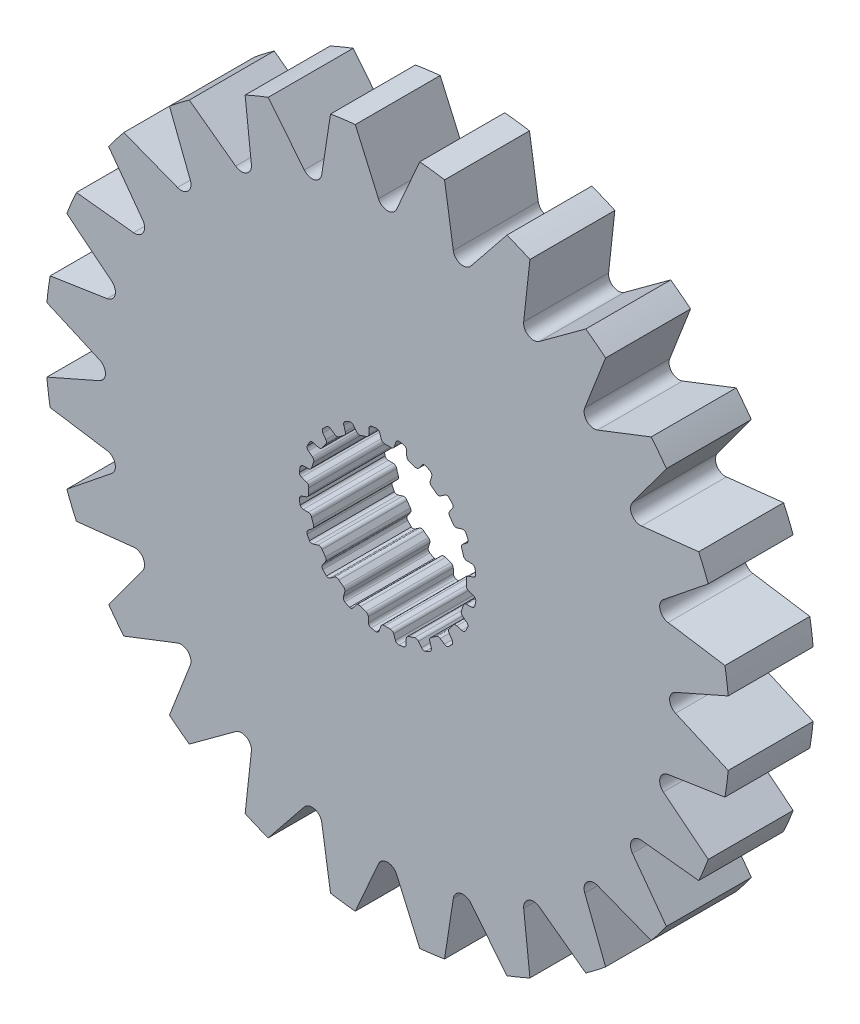
from build123d import *

# Parameters (mm, degrees)
SKETCH1_R           = 12.893401015
BOSS_EXTRUDE1_DEPTH = 1.6002
CUT_EXTRUDE1_DEPTH  = 3.2004


with BuildPart() as part:
    # Sketch1 → Boss-Extrude1 (new body, symmetric)
    with BuildSketch(Plane.XY):
        Circle(SKETCH1_R)
        with BuildLine():
            Line((-0.106949245, 2.969874934), (0.106949245, 2.969874934))
            ThreePointArc((0.106949245, 2.969874934), (0.196343213, 2.986924176), (0.253739238, 3.057547504))
            Line((0.253739238, 3.057547504), (0.315888147, 3.237526941))
            ThreePointArc((0.315888147, 3.237526941), (0.359032156, 3.298322911), (0.4281449, 3.326269005))
            Line((0.4281449, 3.326269005), (0.620027588, 3.2937547))
            ThreePointArc((0.620027588, 3.2937547), (0.689621142, 3.24802576), (0.718272212, 3.169836791))
            Line((0.718272212, 3.169836791), (0.724389167, 2.979527391))
            ThreePointArc((0.724389167, 2.979527391), (0.750934762, 2.9040661), (0.816027049, 2.857568043))
            Line((0.816027049, 2.857568043), (1.019456602, 2.791469774))
            ThreePointArc((1.019456602, 2.791469774), (1.109743823, 2.780060312), (1.186154496, 2.829490741))
            Line((1.186154496, 2.829490741), (1.300878326, 2.981456288))
            ThreePointArc((1.300878326, 2.981456288), (1.360697704, 3.02594446), (1.435063648, 3.031165762))
            Line((1.435063648, 3.031165762), (1.607507455, 2.940947809))
            ThreePointArc((1.607507455, 2.940947809), (1.659563839, 2.875951412), (1.662650905, 2.792735615))
            Line((1.662650905, 2.792735615), (1.609659636, 2.609850378))
            ThreePointArc((1.609659636, 2.609850378), (1.611587176, 2.529879385), (1.659124931, 2.465542482))
            Line((1.659124931, 2.465542482), (1.832172444, 2.339816104))
            ThreePointArc((1.832172444, 2.339816104), (1.914514976, 2.301064775), (2.002460687, 2.32446371))
            Line((2.002460687, 2.32446371), (2.158529469, 2.433539921))
            ThreePointArc((2.158529469, 2.433539921), (2.229168681, 2.457365482), (2.301508367, 2.439350895))
            Line((2.301508367, 2.439350895), (2.437633293, 2.300260456))
            ThreePointArc((2.437633293, 2.300260456), (2.467056864, 2.222358901), (2.444277744, 2.14226202))
            Line((2.444277744, 2.14226202), (2.337365406, 1.984703026))
            ThreePointArc((2.337365406, 1.984703026), (2.314486209, 1.908050449), (2.339816104, 1.832172444))
            Line((2.339816104, 1.832172444), (2.465542482, 1.659124931))
            ThreePointArc((2.465542482, 1.659124931), (2.531880064, 1.596824985), (2.622752074, 1.591901975))
            Line((2.622752074, 1.591901975), (2.804888709, 1.64741171))
            ThreePointArc((2.804888709, 1.64741171), (2.879433095, 1.648242449), (2.942665411, 1.608755366))
            Line((2.942665411, 1.608755366), (3.0291466, 1.434407582))
            ThreePointArc((3.0291466, 1.434407582), (3.033057175, 1.351226417), (2.986641646, 1.282088892))
            Line((2.986641646, 1.282088892), (2.836273564, 1.165279113))
            ThreePointArc((2.836273564, 1.165279113), (2.790827206, 1.099448241), (2.791469774, 1.019456602))
            Line((2.791469774, 1.019456602), (2.857568043, 0.816027049))
            ThreePointArc((2.857568043, 0.816027049), (2.901407091, 0.736276839), (2.986310214, 0.703513784))
            Line((2.986310214, 0.703513784), (3.1766859, 0.700023363))
            ThreePointArc((3.1766859, 0.700023363), (3.247838536, 0.677777961), (3.295773863, 0.620683653))
            Line((3.295773863, 0.620683653), (3.324145932, 0.4281449))
            ThreePointArc((3.324145932, 0.4281449), (3.302160717, 0.347826477), (3.236652255, 0.29641597))
            Line((3.236652255, 0.29641597), (3.057547504, 0.231789562))
            ThreePointArc((3.057547504, 0.231789562), (2.993982591, 0.183224379), (2.969874934, 0.106949245))
            Line((2.969874934, 0.106949245), (2.969874934, -0.106949245))
            ThreePointArc((2.969874934, -0.106949245), (2.986924176, -0.196343213), (3.057547504, -0.253739238))
            Line((3.057547504, -0.253739238), (3.237526941, -0.315888147))
            ThreePointArc((3.237526941, -0.315888147), (3.298322911, -0.359032156), (3.326269005, -0.4281449))
            Line((3.326269005, -0.4281449), (3.2937547, -0.620027588))
            ThreePointArc((3.2937547, -0.620027588), (3.24802576, -0.689621142), (3.169836791, -0.718272212))
            Line((3.169836791, -0.718272212), (2.979527391, -0.724389167))
            ThreePointArc((2.979527391, -0.724389167), (2.9040661, -0.750934762), (2.857568043, -0.816027049))
            Line((2.857568043, -0.816027049), (2.791469774, -1.019456602))
            ThreePointArc((2.791469774, -1.019456602), (2.780060312, -1.109743823), (2.829490741, -1.186154496))
            Line((2.829490741, -1.186154496), (2.981456288, -1.300878326))
            ThreePointArc((2.981456288, -1.300878326), (3.02594446, -1.360697704), (3.031165762, -1.435063648))
            Line((3.031165762, -1.435063648), (2.940947809, -1.607507455))
            ThreePointArc((2.940947809, -1.607507455), (2.875951412, -1.659563839), (2.792735615, -1.662650905))
            Line((2.792735615, -1.662650905), (2.609850378, -1.609659636))
            ThreePointArc((2.609850378, -1.609659636), (2.529879385, -1.611587176), (2.465542482, -1.659124931))
            Line((2.465542482, -1.659124931), (2.339816104, -1.832172444))
            ThreePointArc((2.339816104, -1.832172444), (2.301064775, -1.914514976), (2.32446371, -2.002460687))
            Line((2.32446371, -2.002460687), (2.433539921, -2.158529469))
            ThreePointArc((2.433539921, -2.158529469), (2.457365482, -2.229168681), (2.439350895, -2.301508367))
            Line((2.439350895, -2.301508367), (2.300260456, -2.437633293))
            ThreePointArc((2.300260456, -2.437633293), (2.222358901, -2.467056864), (2.14226202, -2.444277744))
            Line((2.14226202, -2.444277744), (1.984703026, -2.337365406))
            ThreePointArc((1.984703026, -2.337365406), (1.908050449, -2.314486209), (1.832172444, -2.339816104))
            Line((1.832172444, -2.339816104), (1.659124931, -2.465542482))
            ThreePointArc((1.659124931, -2.465542482), (1.596824985, -2.531880064), (1.591901975, -2.622752074))
            Line((1.591901975, -2.622752074), (1.64741171, -2.804888709))
            ThreePointArc((1.64741171, -2.804888709), (1.648242449, -2.879433095), (1.608755366, -2.942665411))
            Line((1.608755366, -2.942665411), (1.434407582, -3.0291466))
            ThreePointArc((1.434407582, -3.0291466), (1.351226417, -3.033057175), (1.282088892, -2.986641646))
            Line((1.282088892, -2.986641646), (1.165279113, -2.836273564))
            ThreePointArc((1.165279113, -2.836273564), (1.099448241, -2.790827206), (1.019456602, -2.791469774))
            Line((1.019456602, -2.791469774), (0.816027049, -2.857568043))
            ThreePointArc((0.816027049, -2.857568043), (0.736276839, -2.901407091), (0.703513784, -2.986310214))
            Line((0.703513784, -2.986310214), (0.700023363, -3.1766859))
            ThreePointArc((0.700023363, -3.1766859), (0.677777961, -3.247838536), (0.620683653, -3.295773863))
            Line((0.620683653, -3.295773863), (0.4281449, -3.324145932))
            ThreePointArc((0.4281449, -3.324145932), (0.347826477, -3.302160717), (0.29641597, -3.236652255))
            Line((0.29641597, -3.236652255), (0.231789562, -3.057547504))
            ThreePointArc((0.231789562, -3.057547504), (0.183224379, -2.993982591), (0.106949245, -2.969874934))
            Line((0.106949245, -2.969874934), (-0.106949245, -2.969874934))
            ThreePointArc((-0.106949245, -2.969874934), (-0.196343213, -2.986924176), (-0.253739238, -3.057547504))
            Line((-0.253739238, -3.057547504), (-0.315888147, -3.237526941))
            ThreePointArc((-0.315888147, -3.237526941), (-0.359032156, -3.298322911), (-0.4281449, -3.326269005))
            Line((-0.4281449, -3.326269005), (-0.620027588, -3.2937547))
            ThreePointArc((-0.620027588, -3.2937547), (-0.689621142, -3.24802576), (-0.718272212, -3.169836791))
            Line((-0.718272212, -3.169836791), (-0.724389167, -2.979527391))
            ThreePointArc((-0.724389167, -2.979527391), (-0.750934762, -2.9040661), (-0.816027049, -2.857568043))
            Line((-0.816027049, -2.857568043), (-1.019456602, -2.791469774))
            ThreePointArc((-1.019456602, -2.791469774), (-1.109743823, -2.780060312), (-1.186154496, -2.829490741))
            Line((-1.186154496, -2.829490741), (-1.300878326, -2.981456288))
            ThreePointArc((-1.300878326, -2.981456288), (-1.360697704, -3.02594446), (-1.435063648, -3.031165762))
            Line((-1.435063648, -3.031165762), (-1.607507455, -2.940947809))
            ThreePointArc((-1.607507455, -2.940947809), (-1.659563839, -2.875951412), (-1.662650905, -2.792735615))
            Line((-1.662650905, -2.792735615), (-1.609659636, -2.609850378))
            ThreePointArc((-1.609659636, -2.609850378), (-1.611587176, -2.529879385), (-1.659124931, -2.465542482))
            Line((-1.659124931, -2.465542482), (-1.832172444, -2.339816104))
            ThreePointArc((-1.832172444, -2.339816104), (-1.914514976, -2.301064775), (-2.002460687, -2.32446371))
            Line((-2.002460687, -2.32446371), (-2.158529469, -2.433539921))
            ThreePointArc((-2.158529469, -2.433539921), (-2.229168681, -2.457365482), (-2.301508367, -2.439350895))
            Line((-2.301508367, -2.439350895), (-2.437633293, -2.300260456))
            ThreePointArc((-2.437633293, -2.300260456), (-2.467056864, -2.222358901), (-2.444277744, -2.14226202))
            Line((-2.444277744, -2.14226202), (-2.337365406, -1.984703026))
            ThreePointArc((-2.337365406, -1.984703026), (-2.314486209, -1.908050449), (-2.339816104, -1.832172444))
            Line((-2.339816104, -1.832172444), (-2.465542482, -1.659124931))
            ThreePointArc((-2.465542482, -1.659124931), (-2.531880064, -1.596824985), (-2.622752074, -1.591901975))
            Line((-2.622752074, -1.591901975), (-2.804888709, -1.64741171))
            ThreePointArc((-2.804888709, -1.64741171), (-2.879433095, -1.648242449), (-2.942665411, -1.608755366))
            Line((-2.942665411, -1.608755366), (-3.0291466, -1.434407582))
            ThreePointArc((-3.0291466, -1.434407582), (-3.033057175, -1.351226417), (-2.986641646, -1.282088892))
            Line((-2.986641646, -1.282088892), (-2.836273564, -1.165279113))
            ThreePointArc((-2.836273564, -1.165279113), (-2.790827206, -1.099448241), (-2.791469774, -1.019456602))
            Line((-2.791469774, -1.019456602), (-2.857568043, -0.816027049))
            ThreePointArc((-2.857568043, -0.816027049), (-2.901407091, -0.736276839), (-2.986310214, -0.703513784))
            Line((-2.986310214, -0.703513784), (-3.1766859, -0.700023363))
            ThreePointArc((-3.1766859, -0.700023363), (-3.247838536, -0.677777961), (-3.295773863, -0.620683653))
            Line((-3.295773863, -0.620683653), (-3.324145932, -0.4281449))
            ThreePointArc((-3.324145932, -0.4281449), (-3.302160717, -0.347826477), (-3.236652255, -0.29641597))
            Line((-3.236652255, -0.29641597), (-3.057547504, -0.231789562))
            ThreePointArc((-3.057547504, -0.231789562), (-2.993982591, -0.183224379), (-2.969874934, -0.106949245))
            Line((-2.969874934, -0.106949245), (-2.969874934, 0.106949245))
            ThreePointArc((-2.969874934, 0.106949245), (-2.986924176, 0.196343213), (-3.057547504, 0.253739238))
            Line((-3.057547504, 0.253739238), (-3.237526941, 0.315888147))
            ThreePointArc((-3.237526941, 0.315888147), (-3.298322911, 0.359032156), (-3.326269005, 0.4281449))
            Line((-3.326269005, 0.4281449), (-3.2937547, 0.620027588))
            ThreePointArc((-3.2937547, 0.620027588), (-3.24802576, 0.689621142), (-3.169836791, 0.718272212))
            Line((-3.169836791, 0.718272212), (-2.979527391, 0.724389167))
            ThreePointArc((-2.979527391, 0.724389167), (-2.9040661, 0.750934762), (-2.857568043, 0.816027049))
            Line((-2.857568043, 0.816027049), (-2.791469774, 1.019456602))
            ThreePointArc((-2.791469774, 1.019456602), (-2.780060312, 1.109743823), (-2.829490741, 1.186154496))
            Line((-2.829490741, 1.186154496), (-2.981456288, 1.300878326))
            ThreePointArc((-2.981456288, 1.300878326), (-3.02594446, 1.360697704), (-3.031165762, 1.435063648))
            Line((-3.031165762, 1.435063648), (-2.940947809, 1.607507455))
            ThreePointArc((-2.940947809, 1.607507455), (-2.875951412, 1.659563839), (-2.792735615, 1.662650905))
            Line((-2.792735615, 1.662650905), (-2.609850378, 1.609659636))
            ThreePointArc((-2.609850378, 1.609659636), (-2.529879385, 1.611587176), (-2.465542482, 1.659124931))
            Line((-2.465542482, 1.659124931), (-2.339816104, 1.832172444))
            ThreePointArc((-2.339816104, 1.832172444), (-2.301064775, 1.914514976), (-2.32446371, 2.002460687))
            Line((-2.32446371, 2.002460687), (-2.433539921, 2.158529469))
            ThreePointArc((-2.433539921, 2.158529469), (-2.457365482, 2.229168681), (-2.439350895, 2.301508367))
            Line((-2.439350895, 2.301508367), (-2.300260456, 2.437633293))
            ThreePointArc((-2.300260456, 2.437633293), (-2.222358901, 2.467056864), (-2.14226202, 2.444277744))
            Line((-2.14226202, 2.444277744), (-1.984703026, 2.337365406))
            ThreePointArc((-1.984703026, 2.337365406), (-1.908050449, 2.314486209), (-1.832172444, 2.339816104))
            Line((-1.832172444, 2.339816104), (-1.659124931, 2.465542482))
            ThreePointArc((-1.659124931, 2.465542482), (-1.596824985, 2.531880064), (-1.591901975, 2.622752074))
            Line((-1.591901975, 2.622752074), (-1.64741171, 2.804888709))
            ThreePointArc((-1.64741171, 2.804888709), (-1.648242449, 2.879433095), (-1.608755366, 2.942665411))
            Line((-1.608755366, 2.942665411), (-1.434407582, 3.0291466))
            ThreePointArc((-1.434407582, 3.0291466), (-1.351226417, 3.033057175), (-1.282088892, 2.986641646))
            Line((-1.282088892, 2.986641646), (-1.165279113, 2.836273564))
            ThreePointArc((-1.165279113, 2.836273564), (-1.099448241, 2.790827206), (-1.019456602, 2.791469774))
            Line((-1.019456602, 2.791469774), (-0.816027049, 2.857568043))
            ThreePointArc((-0.816027049, 2.857568043), (-0.736276839, 2.901407091), (-0.703513784, 2.986310214))
            Line((-0.703513784, 2.986310214), (-0.700023363, 3.1766859))
            ThreePointArc((-0.700023363, 3.1766859), (-0.677777961, 3.247838536), (-0.620683653, 3.295773863))
            Line((-0.620683653, 3.295773863), (-0.4281449, 3.324145932))
            ThreePointArc((-0.4281449, 3.324145932), (-0.347826477, 3.302160717), (-0.29641597, 3.236652255))
            Line((-0.29641597, 3.236652255), (-0.231789562, 3.057547504))
            ThreePointArc((-0.231789562, 3.057547504), (-0.183224379, 2.993982591), (-0.106949245, 2.969874934))
        make_face(mode=Mode.SUBTRACT)
    extrude(amount=BOSS_EXTRUDE1_DEPTH, both=True)

    # Sketch2 → Cut-Extrude1 (cut)
    with BuildSketch(Plane.XY.offset(1.6002)):
        with BuildLine():
            Line((-1.215131366, 12.836013614), (-0.341888634, 10.852413458))
            ThreePointArc((-0.341888634, 10.852413458), (0, 10.629371487), (0.341888634, 10.852413458))
            Line((0.341888634, 10.852413458), (1.215131366, 12.836013614))
            ThreePointArc((1.215131366, 12.836013614), (0, 12.893401015), (-1.215131366, 12.836013614))
        make_face()
        with BuildLine():
            Line((4.495931555, 12.084137917), (3.13905035, 10.394139147))
            ThreePointArc((3.13905035, 10.394139147), (2.751083778, 10.267184437), (2.478572226, 10.571113727))
            Line((2.478572226, 10.571113727), (2.148478018, 12.713136196))
            ThreePointArc((2.148478018, 12.713136196), (3.337057739, 12.454069029), (4.495931555, 12.084137917))
        make_face()
        with BuildLine():
            Line((7.470341439, 10.50874819), (5.722290972, 9.22752143))
            ThreePointArc((5.722290972, 9.22752143), (5.314685744, 9.205305734), (5.130122486, 9.569410064))
            Line((5.130122486, 9.569410064), (5.365672176, 11.723879556))
            ThreePointArc((5.365672176, 11.723879556), (6.446700508, 11.16601282), (7.470341439, 10.50874819))
        make_face()
        with BuildLine():
            Line((9.935659899, 8.217204641), (7.91556692, 7.432063377))
            ThreePointArc((7.91556692, 7.432063377), (7.516100658, 7.516100658), (7.432063377, 7.91556692))
            Line((7.432063377, 7.91556692), (8.217204641, 9.935659899))
            ThreePointArc((8.217204641, 9.935659899), (9.11701129, 9.11701129), (9.935659899, 8.217204641))
        make_face()
        with BuildLine():
            Line((11.723879556, 5.365672176), (9.569410064, 5.130122486))
            ThreePointArc((9.569410064, 5.130122486), (9.205305734, 5.314685744), (9.22752143, 5.722290972))
            Line((9.22752143, 5.722290972), (10.50874819, 7.470341439))
            ThreePointArc((10.50874819, 7.470341439), (11.16601282, 6.446700508), (11.723879556, 5.365672176))
        make_face()
        with BuildLine():
            Line((12.713136196, 2.148478018), (10.571113727, 2.478572226))
            ThreePointArc((10.571113727, 2.478572226), (10.267184437, 2.751083778), (10.394139147, 3.13905035))
            Line((10.394139147, 3.13905035), (12.084137917, 4.495931555))
            ThreePointArc((12.084137917, 4.495931555), (12.454069029, 3.337057739), (12.713136196, 2.148478018))
        make_face()
        with BuildLine():
            Line((12.836013614, -1.215131366), (10.852413458, -0.341888634))
            ThreePointArc((10.852413458, -0.341888634), (10.629371487, 0), (10.852413458, 0.341888634))
            Line((10.852413458, 0.341888634), (12.836013614, 1.215131366))
            ThreePointArc((12.836013614, 1.215131366), (12.893401015, 0), (12.836013614, -1.215131366))
        make_face()
        with BuildLine():
            Line((12.084137917, -4.495931555), (10.394139147, -3.13905035))
            ThreePointArc((10.394139147, -3.13905035), (10.267184437, -2.751083778), (10.571113727, -2.478572226))
            Line((10.571113727, -2.478572226), (12.713136196, -2.148478018))
            ThreePointArc((12.713136196, -2.148478018), (12.454069029, -3.337057739), (12.084137917, -4.495931555))
        make_face()
        with BuildLine():
            Line((10.50874819, -7.470341439), (9.22752143, -5.722290972))
            ThreePointArc((9.22752143, -5.722290972), (9.205305734, -5.314685744), (9.569410064, -5.130122486))
            Line((9.569410064, -5.130122486), (11.723879556, -5.365672176))
            ThreePointArc((11.723879556, -5.365672176), (11.16601282, -6.446700508), (10.50874819, -7.470341439))
        make_face()
        with BuildLine():
            Line((8.217204641, -9.935659899), (7.432063377, -7.91556692))
            ThreePointArc((7.432063377, -7.91556692), (7.516100658, -7.516100658), (7.91556692, -7.432063377))
            Line((7.91556692, -7.432063377), (9.935659899, -8.217204641))
            ThreePointArc((9.935659899, -8.217204641), (9.11701129, -9.11701129), (8.217204641, -9.935659899))
        make_face()
        with BuildLine():
            Line((5.365672176, -11.723879556), (5.130122486, -9.569410064))
            ThreePointArc((5.130122486, -9.569410064), (5.314685744, -9.205305734), (5.722290972, -9.22752143))
            Line((5.722290972, -9.22752143), (7.470341439, -10.50874819))
            ThreePointArc((7.470341439, -10.50874819), (6.446700508, -11.16601282), (5.365672176, -11.723879556))
        make_face()
        with BuildLine():
            Line((2.148478018, -12.713136196), (2.478572226, -10.571113727))
            ThreePointArc((2.478572226, -10.571113727), (2.751083778, -10.267184437), (3.13905035, -10.394139147))
            Line((3.13905035, -10.394139147), (4.495931555, -12.084137917))
            ThreePointArc((4.495931555, -12.084137917), (3.337057739, -12.454069029), (2.148478018, -12.713136196))
        make_face()
        with BuildLine():
            Line((-1.215131366, -12.836013614), (-0.341888634, -10.852413458))
            ThreePointArc((-0.341888634, -10.852413458), (0, -10.629371487), (0.341888634, -10.852413458))
            Line((0.341888634, -10.852413458), (1.215131366, -12.836013614))
            ThreePointArc((1.215131366, -12.836013614), (0, -12.893401015), (-1.215131366, -12.836013614))
        make_face()
        with BuildLine():
            Line((-4.495931555, -12.084137917), (-3.13905035, -10.394139147))
            ThreePointArc((-3.13905035, -10.394139147), (-2.751083778, -10.267184437), (-2.478572226, -10.571113727))
            Line((-2.478572226, -10.571113727), (-2.148478018, -12.713136196))
            ThreePointArc((-2.148478018, -12.713136196), (-3.337057739, -12.454069029), (-4.495931555, -12.084137917))
        make_face()
        with BuildLine():
            Line((-7.470341439, -10.50874819), (-5.722290972, -9.22752143))
            ThreePointArc((-5.722290972, -9.22752143), (-5.314685744, -9.205305734), (-5.130122486, -9.569410064))
            Line((-5.130122486, -9.569410064), (-5.365672176, -11.723879556))
            ThreePointArc((-5.365672176, -11.723879556), (-6.446700508, -11.16601282), (-7.470341439, -10.50874819))
        make_face()
        with BuildLine():
            Line((-9.935659899, -8.217204641), (-7.91556692, -7.432063377))
            ThreePointArc((-7.91556692, -7.432063377), (-7.516100658, -7.516100658), (-7.432063377, -7.91556692))
            Line((-7.432063377, -7.91556692), (-8.217204641, -9.935659899))
            ThreePointArc((-8.217204641, -9.935659899), (-9.11701129, -9.11701129), (-9.935659899, -8.217204641))
        make_face()
        with BuildLine():
            Line((-11.723879556, -5.365672176), (-9.569410064, -5.130122486))
            ThreePointArc((-9.569410064, -5.130122486), (-9.205305734, -5.314685744), (-9.22752143, -5.722290972))
            Line((-9.22752143, -5.722290972), (-10.50874819, -7.470341439))
            ThreePointArc((-10.50874819, -7.470341439), (-11.16601282, -6.446700508), (-11.723879556, -5.365672176))
        make_face()
        with BuildLine():
            Line((-12.713136196, -2.148478018), (-10.571113727, -2.478572226))
            ThreePointArc((-10.571113727, -2.478572226), (-10.267184437, -2.751083778), (-10.394139147, -3.13905035))
            Line((-10.394139147, -3.13905035), (-12.084137917, -4.495931555))
            ThreePointArc((-12.084137917, -4.495931555), (-12.454069029, -3.337057739), (-12.713136196, -2.148478018))
        make_face()
        with BuildLine():
            Line((-12.836013614, 1.215131366), (-10.852413458, 0.341888634))
            ThreePointArc((-10.852413458, 0.341888634), (-10.629371487, 0), (-10.852413458, -0.341888634))
            Line((-10.852413458, -0.341888634), (-12.836013614, -1.215131366))
            ThreePointArc((-12.836013614, -1.215131366), (-12.893401015, 0), (-12.836013614, 1.215131366))
        make_face()
        with BuildLine():
            Line((-12.084137917, 4.495931555), (-10.394139147, 3.13905035))
            ThreePointArc((-10.394139147, 3.13905035), (-10.267184437, 2.751083778), (-10.571113727, 2.478572226))
            Line((-10.571113727, 2.478572226), (-12.713136196, 2.148478018))
            ThreePointArc((-12.713136196, 2.148478018), (-12.454069029, 3.337057739), (-12.084137917, 4.495931555))
        make_face()
        with BuildLine():
            Line((-10.50874819, 7.470341439), (-9.22752143, 5.722290972))
            ThreePointArc((-9.22752143, 5.722290972), (-9.205305734, 5.314685744), (-9.569410064, 5.130122486))
            Line((-9.569410064, 5.130122486), (-11.723879556, 5.365672176))
            ThreePointArc((-11.723879556, 5.365672176), (-11.16601282, 6.446700508), (-10.50874819, 7.470341439))
        make_face()
        with BuildLine():
            Line((-8.217204641, 9.935659899), (-7.432063377, 7.91556692))
            ThreePointArc((-7.432063377, 7.91556692), (-7.516100658, 7.516100658), (-7.91556692, 7.432063377))
            Line((-7.91556692, 7.432063377), (-9.935659899, 8.217204641))
            ThreePointArc((-9.935659899, 8.217204641), (-9.11701129, 9.11701129), (-8.217204641, 9.935659899))
        make_face()
        with BuildLine():
            Line((-5.365672176, 11.723879556), (-5.130122486, 9.569410064))
            ThreePointArc((-5.130122486, 9.569410064), (-5.314685744, 9.205305734), (-5.722290972, 9.22752143))
            Line((-5.722290972, 9.22752143), (-7.470341439, 10.50874819))
            ThreePointArc((-7.470341439, 10.50874819), (-6.446700508, 11.16601282), (-5.365672176, 11.723879556))
        make_face()
        with BuildLine():
            Line((-2.148478018, 12.713136196), (-2.478572226, 10.571113727))
            ThreePointArc((-2.478572226, 10.571113727), (-2.751083778, 10.267184437), (-3.13905035, 10.394139147))
            Line((-3.13905035, 10.394139147), (-4.495931555, 12.084137917))
            ThreePointArc((-4.495931555, 12.084137917), (-3.337057739, 12.454069029), (-2.148478018, 12.713136196))
        make_face()
    extrude(amount=-CUT_EXTRUDE1_DEPTH, mode=Mode.SUBTRACT)


solid = part.part
